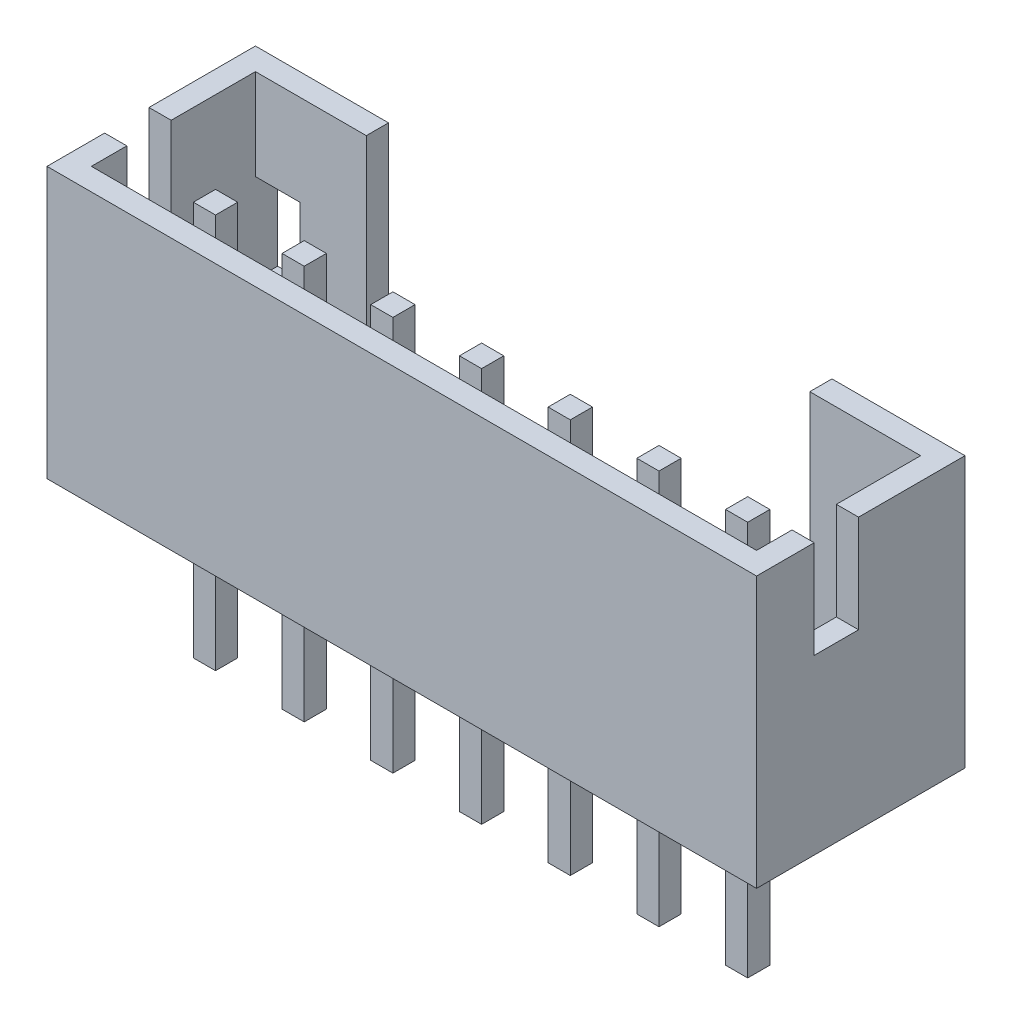
from build123d import *

# Parameters (mm, degrees)
SKETCH1_W         = 16
SKETCH1_H         = 4.7
CASING_DEPTH      = 6.1
CASING_SHELL_T    = -0.5
SKETCH2_W         = 0.5
SKETCH2_H         = 0.5
PINS_DEPTH        = 5
PINS_DEPTH_BACK   = 3.9
PINS_2_DEPTH      = 5
PINS_2_DEPTH_BACK = 3.9
PINS_3_DEPTH      = 5
PINS_3_DEPTH_BACK = 3.9
PINS_4_DEPTH      = 5
PINS_4_DEPTH_BACK = 3.9
PINS_5_DEPTH      = 5
PINS_5_DEPTH_BACK = 3.9
PINS_6_DEPTH      = 5
PINS_6_DEPTH_BACK = 3.9
PINS_7_DEPTH      = 5
PINS_7_DEPTH_BACK = 3.9
SKETCH3_W         = 10
SKETCH3_H         = 4.6
SKETCH3_W_2       = 1
SKETCH3_H_2       = 2
SHAPE_CUT1_DEPTH  = 0.5
SKETCH4_W         = 1
SKETCH4_H         = 2.2
SHAPE_CUT2_DEPTH  = 15.5


with BuildPart() as part:
    # Sketch1 → casing (new body)
    with BuildSketch(Plane(origin=(0, 0, 0), x_dir=(1, 0, 0), z_dir=(0, 1, 0))):
        Rectangle(SKETCH1_W, SKETCH1_H)
    extrude(amount=CASING_DEPTH)

    # casing_shell
    casing_shell_openings = [part.faces().sort_by_distance(p)[0] for p in [
        (0, 6.1, 0),
    ]]
    offset(amount=CASING_SHELL_T, openings=casing_shell_openings, kind=Kind.INTERSECTION)

    # Sketch3 → shape_cut1 (cut)
    with BuildSketch(Plane(origin=(0, 0, -2.35), x_dir=(-1, 0, 0), z_dir=(0, 0, -1))):
        with Locations((0, 3.8)):
            Rectangle(SKETCH3_W, SKETCH3_H)
        with Locations((-7, 3.05)):
            Rectangle(SKETCH3_W_2, SKETCH3_H_2)
        with Locations((7, 3.05)):
            Rectangle(SKETCH3_W_2, SKETCH3_H_2)
    extrude(amount=-SHAPE_CUT1_DEPTH, mode=Mode.SUBTRACT)

    # Sketch4 → shape_cut2 (cut)
    with BuildSketch(Plane.ZY.offset(8)):
        with Locations((0.55, 5)):
            Rectangle(SKETCH4_W, SKETCH4_H)
    shape_cut2 = extrude(amount=-SHAPE_CUT2_DEPTH, mode=Mode.SUBTRACT)

    # shape_cut2m: shape_cut2 across plane
    add(shape_cut2.mirror(Plane(origin=(0, 0, 0), x_dir=(0, 0, 1), z_dir=(1, 0, 0))), mode=Mode.SUBTRACT)


with BuildPart() as body_2:
    # Sketch2 → pins (new body, two sides)
    with BuildSketch(Plane(origin=(0, 0.5, 0), x_dir=(1, 0, 0), z_dir=(0, 1, 0))) as pins_sk:
        with Locations((-6, -0.55)):
            Rectangle(SKETCH2_W, SKETCH2_H)
    extrude(amount=PINS_DEPTH)
    extrude(pins_sk.sketch, amount=-PINS_DEPTH_BACK)


with BuildPart() as body_3:
    # Sketch2 → pins 2 (new body, two sides)
    with BuildSketch(Plane(origin=(0, 0.5, 0), x_dir=(1, 0, 0), z_dir=(0, 1, 0))) as pins_2_sk:
        with Locations((-4, -0.55)):
            Rectangle(SKETCH2_W, SKETCH2_H)
    extrude(amount=PINS_2_DEPTH)
    extrude(pins_2_sk.sketch, amount=-PINS_2_DEPTH_BACK)


with BuildPart() as body_4:
    # Sketch2 → pins 3 (new body, two sides)
    with BuildSketch(Plane(origin=(0, 0.5, 0), x_dir=(1, 0, 0), z_dir=(0, 1, 0))) as pins_3_sk:
        with Locations((-2, -0.55)):
            Rectangle(SKETCH2_W, SKETCH2_H)
    extrude(amount=PINS_3_DEPTH)
    extrude(pins_3_sk.sketch, amount=-PINS_3_DEPTH_BACK)


with BuildPart() as body_5:
    # Sketch2 → pins 4 (new body, two sides)
    with BuildSketch(Plane(origin=(0, 0.5, 0), x_dir=(1, 0, 0), z_dir=(0, 1, 0))) as pins_4_sk:
        with Locations((0, -0.55)):
            Rectangle(SKETCH2_W, SKETCH2_H)
    extrude(amount=PINS_4_DEPTH)
    extrude(pins_4_sk.sketch, amount=-PINS_4_DEPTH_BACK)


with BuildPart() as body_6:
    # Sketch2 → pins 5 (new body, two sides)
    with BuildSketch(Plane(origin=(0, 0.5, 0), x_dir=(1, 0, 0), z_dir=(0, 1, 0))) as pins_5_sk:
        with Locations((2, -0.55)):
            Rectangle(SKETCH2_W, SKETCH2_H)
    extrude(amount=PINS_5_DEPTH)
    extrude(pins_5_sk.sketch, amount=-PINS_5_DEPTH_BACK)


with BuildPart() as body_7:
    # Sketch2 → pins 6 (new body, two sides)
    with BuildSketch(Plane(origin=(0, 0.5, 0), x_dir=(1, 0, 0), z_dir=(0, 1, 0))) as pins_6_sk:
        with Locations((4, -0.55)):
            Rectangle(SKETCH2_W, SKETCH2_H)
    extrude(amount=PINS_6_DEPTH)
    extrude(pins_6_sk.sketch, amount=-PINS_6_DEPTH_BACK)


with BuildPart() as body_8:
    # Sketch2 → pins 7 (new body, two sides)
    with BuildSketch(Plane(origin=(0, 0.5, 0), x_dir=(1, 0, 0), z_dir=(0, 1, 0))) as pins_7_sk:
        with Locations((6, -0.55)):
            Rectangle(SKETCH2_W, SKETCH2_H)
    extrude(amount=PINS_7_DEPTH)
    extrude(pins_7_sk.sketch, amount=-PINS_7_DEPTH_BACK)


solid = Compound([part.part, body_2.part, body_3.part, body_4.part, body_5.part, body_6.part, body_7.part, body_8.part])
